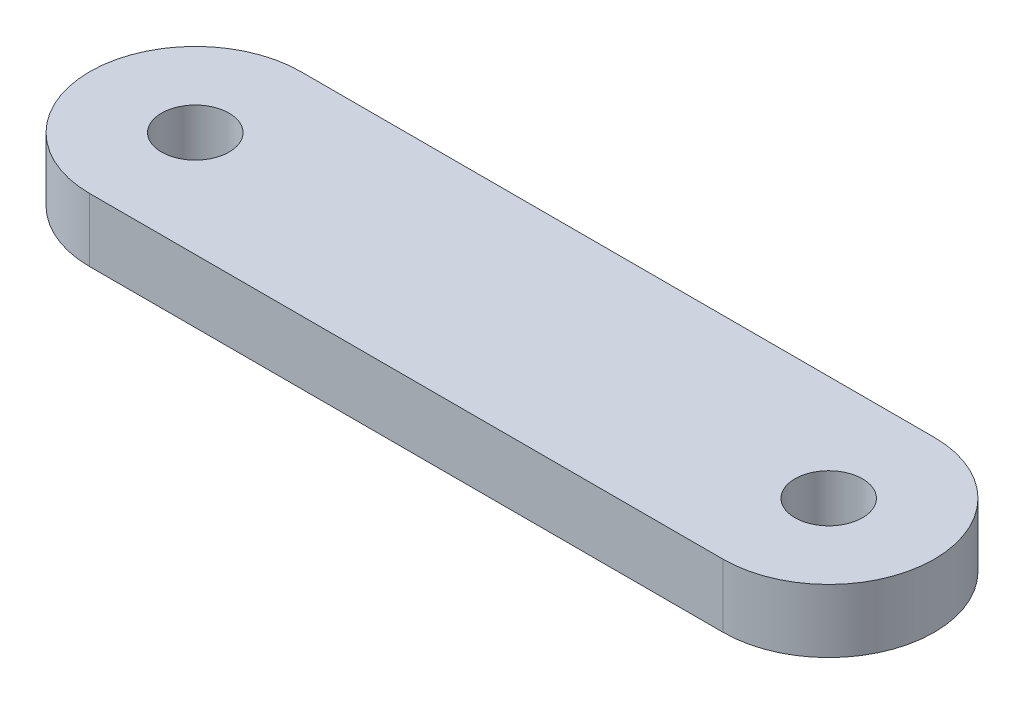
from build123d import *

# Parameters (mm, degrees)
SKETCH_1_R      = 1.6
EXTRUDE_1_DEPTH = 3


with BuildPart() as part:
    # 草图1 → 凸台-拉伸1 (new body)
    with BuildSketch(Plane(origin=(0, 0, 0), x_dir=(1, 0, 0), z_dir=(0, 1, 0))):
        with BuildLine():
            Line((-30, 5), (0, 5))
            ThreePointArc((0, 5), (5, 0), (0, -5))
            Line((0, -5), (-30, -5))
            ThreePointArc((-30, -5), (-35, 0), (-30, 5))
        make_face()
        with Locations((-30, 0)):
            Circle(SKETCH_1_R, mode=Mode.SUBTRACT)
        Circle(SKETCH_1_R, mode=Mode.SUBTRACT)
    extrude(amount=EXTRUDE_1_DEPTH)


solid = part.part
